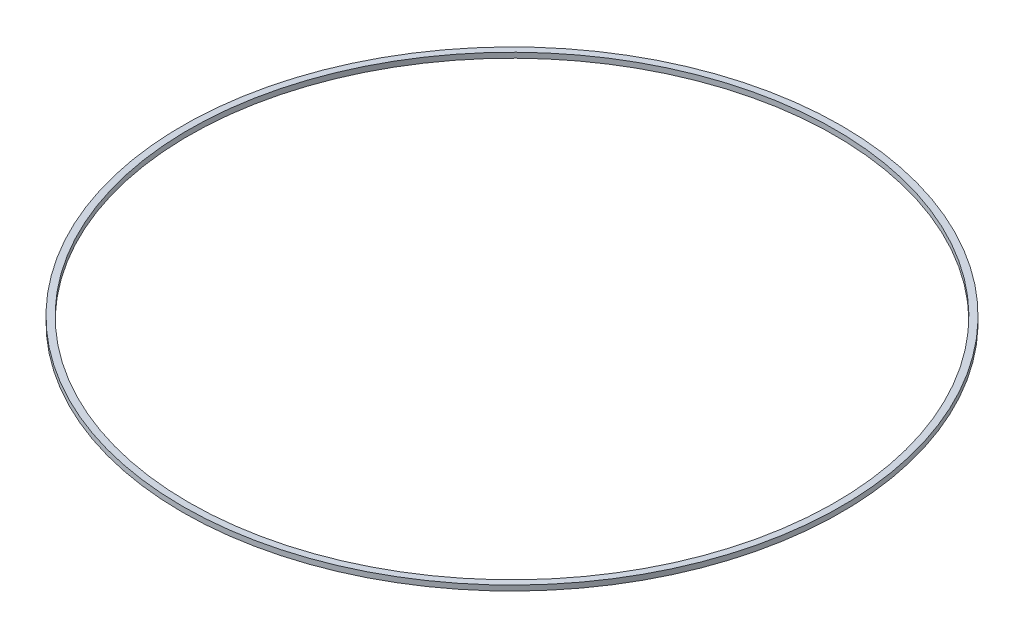
from build123d import *

# Parameters (mm, degrees)
SKETCH1_R           = 25.4
SKETCH1_R_2         = 24.9
BOSS_EXTRUDE1_DEPTH = 0.4


with BuildPart() as part:
    # Sketch1 → Boss-Extrude1 (new body)
    with BuildSketch(Plane(origin=(0, 0, 0), x_dir=(1, 0, 0), z_dir=(0, 1, 0))):
        Circle(SKETCH1_R)
        Circle(SKETCH1_R_2, mode=Mode.SUBTRACT)
    extrude(amount=BOSS_EXTRUDE1_DEPTH)


solid = part.part
